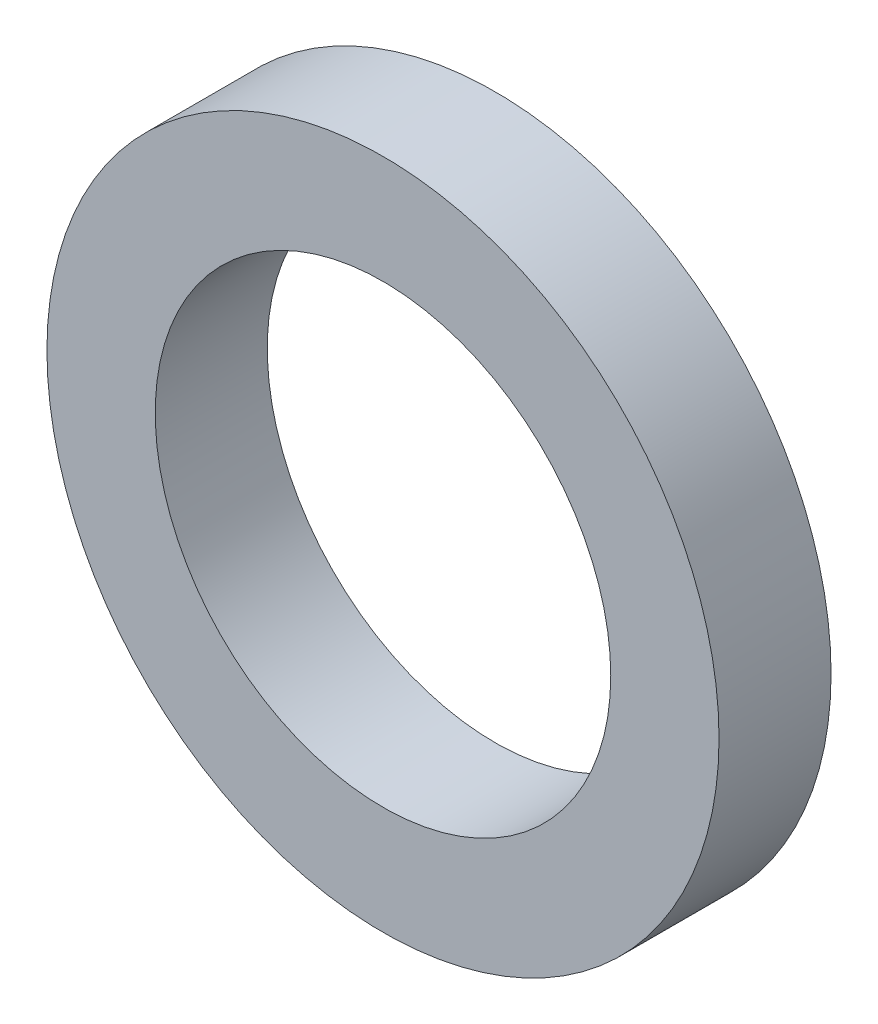
from build123d import *

# Parameters (mm, degrees)
SKETCH_1_R          = 4.5
EXTRUDE_1_DEPTH     = 1.5
SKETCH_2_R          = 3.05
CUT_EXTRUDE_1_DEPTH = 2.5


with BuildPart() as part:
    # 草图1 → 凸台-拉伸1 (new body)
    with BuildSketch(Plane.XY):
        Circle(SKETCH_1_R)
    extrude(amount=EXTRUDE_1_DEPTH)

    # 草图2 → 切除-拉伸1 (cut, through all)
    with BuildSketch(Plane.XY.offset(1.5)):
        Circle(SKETCH_2_R)
    extrude(amount=-CUT_EXTRUDE_1_DEPTH, mode=Mode.SUBTRACT)


solid = part.part
